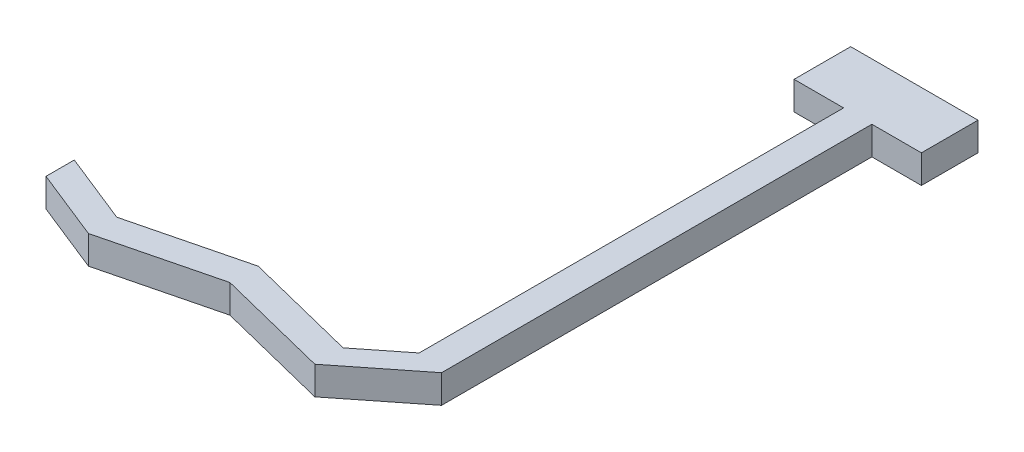
from build123d import *

# Parameters (mm, degrees)
BOSS_EXTRUDE1_DEPTH = 2


with BuildPart() as part:
    # Sketch1 → Boss-Extrude1 (new body)
    with BuildSketch(Plane(origin=(0, 0, 0), x_dir=(1, 0, 0), z_dir=(0, 1, 0))):
        Polygon((0, 0), (0, 30.416038665), (3.5, 30.416038665), (3.5, 34.416038665), (-5.5, 34.416038665), (-5.5, 30.416038665), (-2, 30.416038665), (-2, 0.416038665), (-5, -1.959903338), (-13, 0.040096662), (-21, -1.959903338), (-26, 0.040096662), (-26, -1.959903338), (-21, -3.959903338), (-13, -1.959903338), (-5, -3.959903338), align=None)
    extrude(amount=BOSS_EXTRUDE1_DEPTH)


solid = part.part
